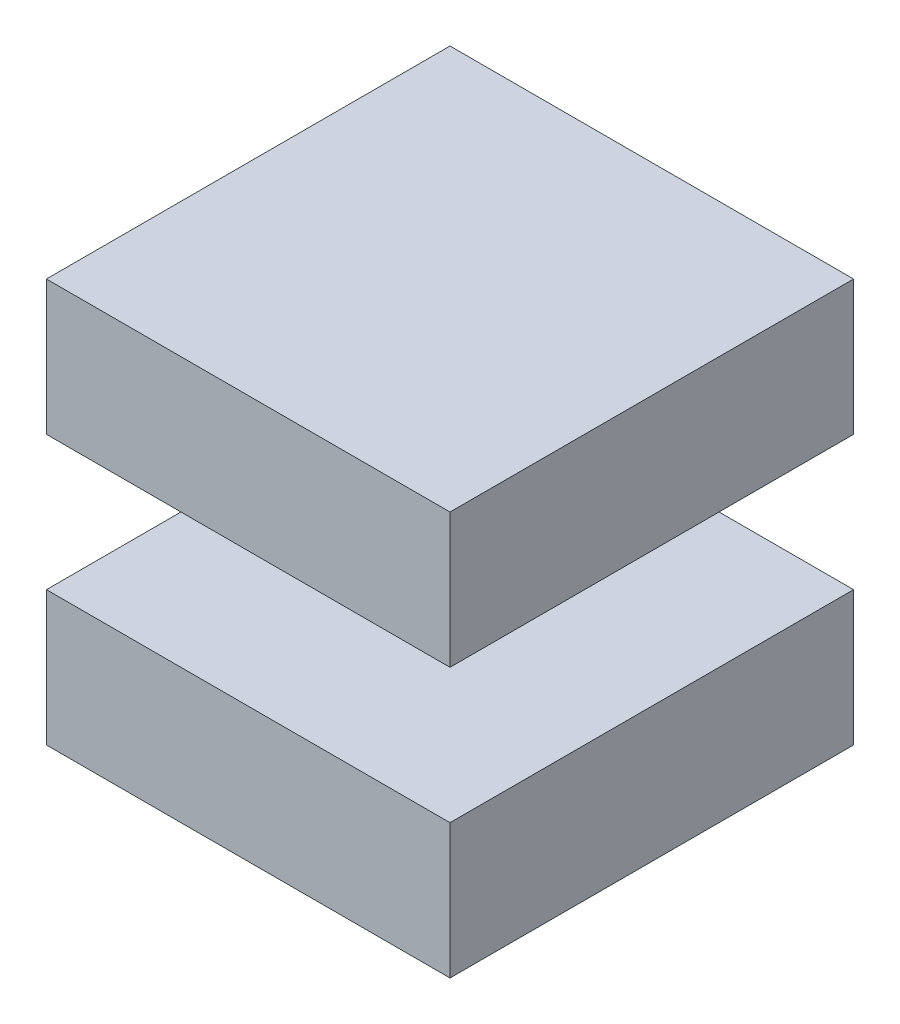
from build123d import *

# Parameters (mm, degrees)
SKETCH1_W           = 60
SKETCH1_H           = 60
BOSS_EXTRUDE1_DEPTH = 60
SKETCH2_W           = 20
SKETCH2_H           = 20
CUT_EXTRUDE1_DEPTH  = 60
SKETCH3_W           = 20
SKETCH3_H           = 20
CUT_EXTRUDE2_DEPTH  = 20
SKETCH4_W           = 20
SKETCH4_H           = 20
CUT_EXTRUDE3_DEPTH  = 20
SKETCH5_W           = 20
SKETCH5_H           = 20
BOSS_EXTRUDE2_DEPTH = 20


with BuildPart() as part:
    # Sketch1 → Boss-Extrude1 (new body)
    with BuildSketch(Plane.XY):
        with Locations((30, 30)):
            Rectangle(SKETCH1_W, SKETCH1_H)
    extrude(amount=BOSS_EXTRUDE1_DEPTH)

    # Sketch2 → Cut-Extrude1 (cut)
    with BuildSketch(Plane.XY.offset(60)):
        with Locations((10, 30)):
            Rectangle(SKETCH2_W, SKETCH2_H)
        with Locations((50, 30)):
            Rectangle(SKETCH2_W, SKETCH2_H)
    extrude(amount=-CUT_EXTRUDE1_DEPTH, mode=Mode.SUBTRACT)

    # Sketch3 → Cut-Extrude2 (cut)
    with BuildSketch(Plane.ZY):
        with Locations((30, 50)):
            Rectangle(SKETCH3_W, SKETCH3_H)
        with Locations((30, 10)):
            Rectangle(SKETCH3_W, SKETCH3_H)
    extrude(amount=-CUT_EXTRUDE2_DEPTH, mode=Mode.SUBTRACT)

    # Sketch4 → Cut-Extrude3 (cut)
    with BuildSketch(Plane.ZY.offset(-20)):
        with Locations((10, 30)):
            Rectangle(SKETCH4_W, SKETCH4_H)
        with Locations((50, 30)):
            Rectangle(SKETCH4_W, SKETCH4_H)
    extrude(amount=-CUT_EXTRUDE3_DEPTH, mode=Mode.SUBTRACT)

    # Sketch5 → Boss-Extrude2 (add)
    with BuildSketch(Plane.ZY.offset(-20)):
        with Locations((30, 50)):
            Rectangle(SKETCH5_W, SKETCH5_H)
        with Locations((30, 10)):
            Rectangle(SKETCH5_W, SKETCH5_H)
    extrude(amount=BOSS_EXTRUDE2_DEPTH)


solid = part.part
